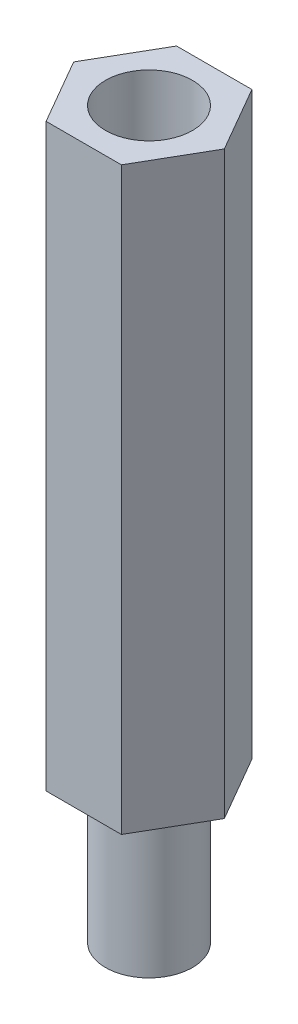
from build123d import *

# Parameters (mm, degrees)
BOSS_EXTRUDE1_DEPTH = 20
SKETCH2_R           = 1.5
BOSS_EXTRUDE2_DEPTH = 5
CUT_EXTRUDE1_START  = -20
SKETCH2_2_R         = 1.5
CUT_EXTRUDE1_DEPTH  = 5


with BuildPart() as part:
    # Sketch1 → Boss-Extrude1 (new body)
    with BuildSketch(Plane(origin=(0, 0, 0), x_dir=(1, 0, 0), z_dir=(0, 1, 0))):
        Polygon((2.598076211, 0), (1.299038106, 2.25), (-1.299038106, 2.25), (-2.598076211, 0), (-1.299038106, -2.25), (1.299038106, -2.25), align=None)
    extrude(amount=BOSS_EXTRUDE1_DEPTH)

    # Sketch2 → Boss-Extrude2 (add)
    with BuildSketch(Plane.XZ):
        Circle(SKETCH2_R)
    extrude(amount=BOSS_EXTRUDE2_DEPTH)

    # Sketch2_2 → Cut-Extrude1 (cut)
    with BuildSketch(Plane.XZ.offset(CUT_EXTRUDE1_START)):
        Circle(SKETCH2_2_R)
    extrude(amount=CUT_EXTRUDE1_DEPTH, mode=Mode.SUBTRACT)


solid = part.part
